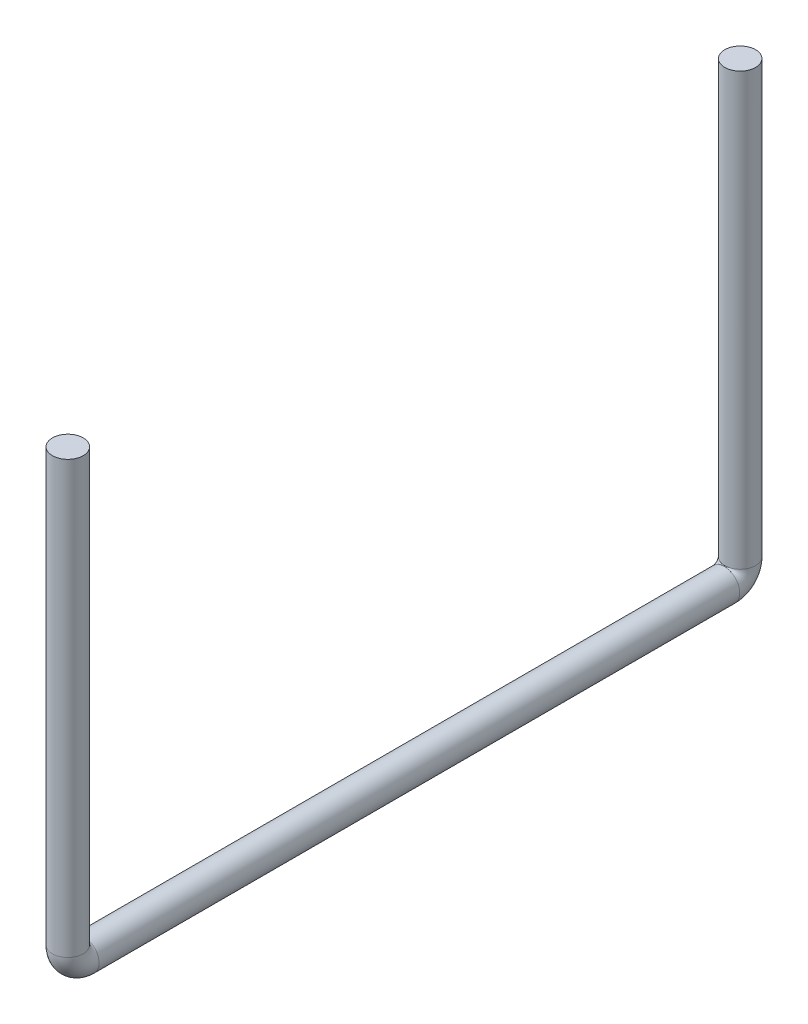
from build123d import *

# Parameters (mm, degrees)
SKETCH1_R           = 12.7
BOSS_EXTRUDE1_DEPTH = 528.066
SKETCH1_4_R         = 12.7
REVOLVE20_ANGLE     = 90
SKETCH8_R           = 12.7
BOSS_EXTRUDE2_DEPTH = 355.6


with BuildPart() as part:
    # Sketch1 → Boss-Extrude1 (new body)
    with BuildSketch(Plane.XY):
        Circle(SKETCH1_R)
    extrude(amount=BOSS_EXTRUDE1_DEPTH)


with BuildPart() as body_2:
    # Sketch1_4 → Revolve20 (revolve)
    with BuildSketch(Plane.XY):
        Circle(SKETCH1_4_R)
    revolve(axis=Axis((1001.058274446, 13.07577549, 0), (1, 0, 0)), revolution_arc=REVOLVE20_ANGLE)

    # Sketch8 → Boss-Extrude2 (add)
    with BuildSketch(Plane(origin=(0, 13.07577549, 0), x_dir=(1, 0, 0), z_dir=(0, 1, 0))):
        with Locations((0, 13.07577549)):
            Circle(SKETCH8_R)
    extrude(amount=BOSS_EXTRUDE2_DEPTH)


with BuildPart() as body_3:
    # Mirror2: mirrored copy
    add(body_2.part.mirror(Plane.XY.offset(264.033)))


solid = Compound([part.part, body_2.part, body_3.part])
